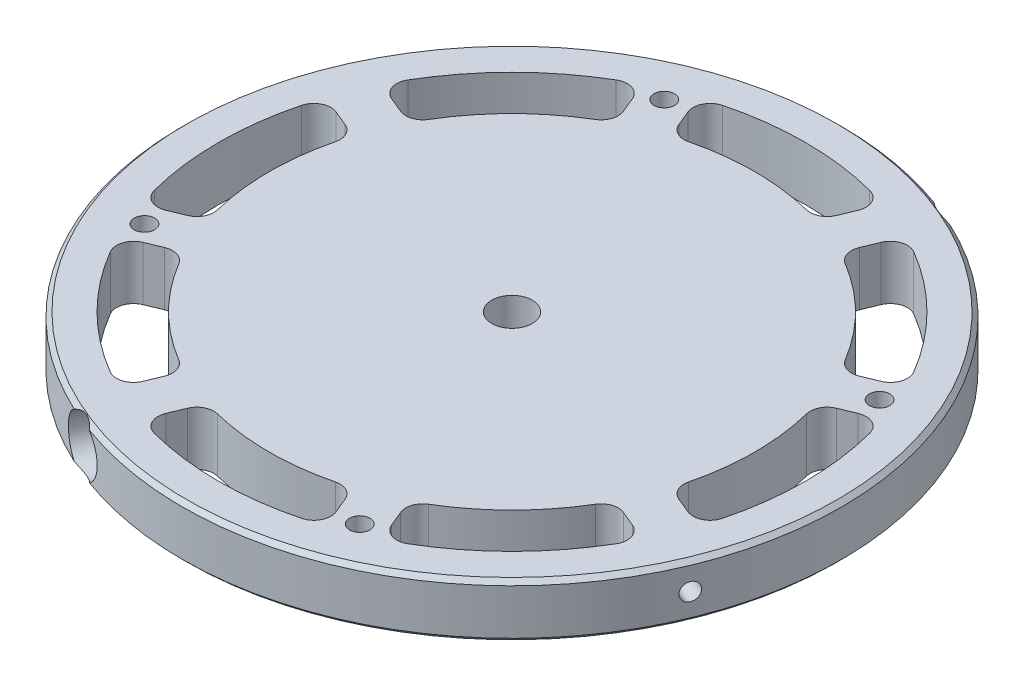
from build123d import *

# Parameters (mm, degrees)
SKETCH2_W                   = 77.55
SKETCH2_H                   = 12.7
F_12_0_189_DIAMETER_HOLE1_D = 4.8006
CIRPATTERN3_COUNT           = 4
CUT_EXTRUDE1_DEPTH          = 13.7
FILLET1_R                   = 4
CIRPATTERN4_COUNT           = 8
FILLET1_OF_CIRPATTERN4_R    = 4
CHAMFER1_SIZE               = 1
SKETCH15_W                  = 2.0447
SKETCH15_H                  = 101.323957926
SKETCH19_R                  = 6.25
CUT_EXTRUDE3_DEPTH          = 5
CIRPATTERN5_COUNT           = 2
CIRPATTERN6_COUNT           = 2
SKETCH22_R                  = 4.765
CUT_EXTRUDE4_DEPTH          = 12.8


with BuildPart() as part:
    # Sketch2 → Revolve1 (revolve)
    with BuildSketch(Plane(origin=(0, 0, 0), x_dir=(0, 0, -1), z_dir=(1, 0, 0))):
        with Locations((-38.775, 6.35)):
            Rectangle(SKETCH2_W, SKETCH2_H)
    revolve(axis=Axis((0, -0.888756804, 0), (0, 1, 0)))

    # #12 (0.189) Diameter Hole1 (through all)
    with Locations(Plane(origin=(0, 12.7, 0), x_dir=(1, 0, 0), z_dir=(0, 1, 0))):
        with Locations((-25.333643223, 61.160825052)):
            f_12_0_189_diameter_hole1 = Hole(F_12_0_189_DIAMETER_HOLE1_D / 2)

    # CirPattern3: #12 (0.189) Diameter Hole1 ×4 about axis
    cirpattern3_axis = Axis((0, 0, 0), (0, 1, 0))
    for i in range(1, CIRPATTERN3_COUNT):
        add(f_12_0_189_diameter_hole1.rotate(cirpattern3_axis, i * 360 / CIRPATTERN3_COUNT), mode=Mode.SUBTRACT)

    # Sketch8 → Cut-Extrude1 (cut, through all)
    with BuildSketch(Plane(origin=(0, 12.7, 0), x_dir=(1, 0, 0), z_dir=(0, 1, 0))):
        with BuildLine():
            Line((-17.167098173, 54.510670885), (-21.735525784, 65.539830782))
            ThreePointArc((-21.735525784, 65.539830782), (0, 69.05), (21.735525784, 65.539830782))
            Line((21.735525784, 65.539830782), (17.167098173, 54.510670885))
            ThreePointArc((17.167098173, 54.510670885), (0, 57.15), (-17.167098173, 54.510670885))
        make_face()
    cut_extrude1 = extrude(amount=-CUT_EXTRUDE1_DEPTH, mode=Mode.SUBTRACT)

    # Fillet1
    fillet1_edges = [part.edges().sort_by_distance(p)[0] for p in [
        (17.167098173, 6.35, -54.510670885),
        (-17.167098173, 6.35, -54.510670885),
        (-21.735525784, 6.35, -65.539830782),
        (21.735525784, 6.35, -65.539830782),
    ]]
    fillet(fillet1_edges, radius=FILLET1_R)

    # CirPattern4: Cut-Extrude1 ×8 about axis
    cirpattern4_axis = Axis((0, 0, 0), (0, 1, 0))
    for i in range(1, CIRPATTERN4_COUNT):
        add(cut_extrude1.rotate(cirpattern4_axis, i * 360 / CIRPATTERN4_COUNT), mode=Mode.SUBTRACT)

    # Fillet1 of CirPattern4
    fillet1_of_cirpattern4_edges = [part.edges().sort_by_distance(p)[0] for p in [
        (-26.405893498, 6.35, -50.683836561),
        (-50.683836561, 6.35, -26.405893498),
        (-61.712996458, 6.35, -30.974321109),
        (-30.974321109, 6.35, -61.712996458),
        (-54.510670885, 6.35, -17.167098173),
        (-54.510670885, 6.35, 17.167098173),
        (-65.539830782, 6.35, 21.735525784),
        (-65.539830782, 6.35, -21.735525784),
        (-50.683836561, 6.35, 26.405893498),
        (-26.405893498, 6.35, 50.683836561),
        (-30.974321109, 6.35, 61.712996458),
        (-61.712996458, 6.35, 30.974321109),
        (-17.167098173, 6.35, 54.510670885),
        (17.167098173, 6.35, 54.510670885),
        (21.735525784, 6.35, 65.539830782),
        (-21.735525784, 6.35, 65.539830782),
        (26.405893498, 6.35, 50.683836561),
        (50.683836561, 6.35, 26.405893498),
        (61.712996458, 6.35, 30.974321109),
        (30.974321109, 6.35, 61.712996458),
        (54.510670885, 6.35, 17.167098173),
        (54.510670885, 6.35, -17.167098173),
        (65.539830782, 6.35, -21.735525784),
        (65.539830782, 6.35, 21.735525784),
        (50.683836561, 6.35, -26.405893498),
        (26.405893498, 6.35, -50.683836561),
        (30.974321109, 6.35, -61.712996458),
        (61.712996458, 6.35, -30.974321109),
    ]]
    fillet(fillet1_of_cirpattern4_edges, radius=FILLET1_OF_CIRPATTERN4_R)

    # Chamfer1
    chamfer1_edges = [part.edges().sort_by_distance(p)[0] for p in [
        (0, 12.7, -77.55),
        (0, 0, -77.55),
    ]]
    chamfer(chamfer1_edges, length=CHAMFER1_SIZE)

    # Sketch15 → #20 (0.161) Diameter Hole1 (revolve, cut)
    with BuildSketch(Plane(origin=(0, 6.35, 0), x_dir=(-0.382683432, 0, 0.923879533), z_dir=(0, 1, 0))):
        with Locations((1.02235, 50.661978963)):
            Rectangle(SKETCH15_W, SKETCH15_H)
    revolve(axis=Axis((-5.866635031, 6.35, -2.430039796), (0.923879533, 0, 0.382683432)), mode=Mode.SUBTRACT)

    # Sketch19 → Cut-Extrude3 (cut)
    with BuildSketch(Plane(origin=(29.67710018, 0, -71.646857746), x_dir=(-0.923879533, 0, -0.382683432), z_dir=(0.382683432, 0, -0.923879533))):
        with Locations((0, 6.35)):
            Circle(SKETCH19_R)
    cut_extrude3 = extrude(amount=-CUT_EXTRUDE3_DEPTH, mode=Mode.SUBTRACT)

    # CirPattern5: Cut-Extrude3 ×2 about axis
    cirpattern5_axis = Axis((0, -0.888756804, 0), (0, 1, 0))
    for i in range(1, CIRPATTERN5_COUNT):
        add(cut_extrude3.rotate(cirpattern5_axis, i * 360 / CIRPATTERN5_COUNT), mode=Mode.SUBTRACT)

    # Sketch21 → #10-24 Tapped Hole1 (revolve, cut)
    with BuildSketch(Plane(origin=(-27.763683018, 6.35, 67.027460084), x_dir=(0.923879533, 0, 0.382683432), z_dir=(0, 1, 0))):
        Polygon((0, 0), (0, 51.940824014), (1.89865, 50.8), (1.89865, 0), align=None)
    f_10_24_tapped_hole1 = revolve(axis=Axis((-30.193722814, 6.35, 72.894095115), (0.382683432, 0, -0.923879533)), mode=Mode.SUBTRACT)

    # CirPattern6: #10-24 Tapped Hole1 ×2 about axis
    cirpattern6_axis = Axis((0, -0.888756804, 0), (0, 1, 0))
    for i in range(1, CIRPATTERN6_COUNT):
        add(f_10_24_tapped_hole1.rotate(cirpattern6_axis, i * 360 / CIRPATTERN6_COUNT), mode=Mode.SUBTRACT)

    # Sketch22 → Cut-Extrude4 (cut)
    with BuildSketch(Plane(origin=(0, 12.7, 0), x_dir=(1, 0, 0), z_dir=(0, 1, 0))):
        Circle(SKETCH22_R)
    extrude(amount=-CUT_EXTRUDE4_DEPTH, mode=Mode.SUBTRACT)


solid = part.part
